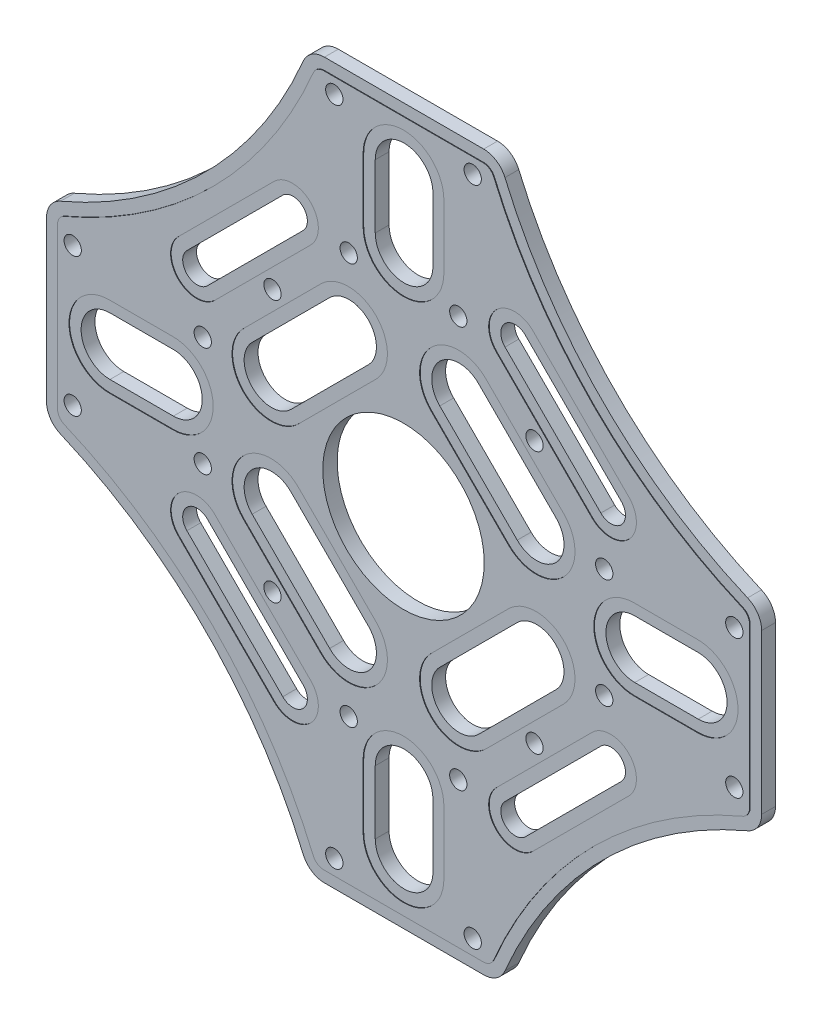
from build123d import *

# Parameters (mm, degrees)
CROQUIS1_R              = 14
SALIENTE_EXTRUIR1_DEPTH = 1.25
REDONDEO1_R             = 4
CORTAR_EXTRUIR1_DEPTH   = 0.1
CORTAR_EXTRUIR2_DEPTH   = 0.1
CROQUIS4_R              = 1.5
CORTAR_EXTRUIR3_DEPTH   = 10
CROQUIS5_R              = 1.5
CORTAR_EXTRUIR4_DEPTH   = 10


with BuildPart() as part:
    # Croquis1 → Saliente-Extruir1 (new body, symmetric)
    with BuildSketch(Plane.XY):
        with BuildLine():
            Line((16.5, -62), (-16.5, -62))
            ThreePointArc((-16.5, -62), (-34.432963769, -34.432963769), (-62, -16.5))
            Line((-62, -16.5), (-62, 16.5))
            ThreePointArc((-62, 16.5), (-34.432963769, 34.432963769), (-16.5, 62))
            Line((-16.5, 62), (16.5, 62))
            ThreePointArc((16.5, 62), (34.432963769, 34.432963769), (62, 16.5))
            Line((62, 16.5), (62, -16.5))
            ThreePointArc((62, -16.5), (34.432963769, -34.432963769), (16.5, -62))
        make_face()
        Circle(CROQUIS1_R, mode=Mode.SUBTRACT)
        with BuildLine():
            Line((5, 51), (5, 40))
            ThreePointArc((5, 40), (0, 35), (-5, 40))
            Line((-5, 40), (-5, 51))
            ThreePointArc((-5, 51), (0, 56), (5, 51))
        make_face(mode=Mode.SUBTRACT)
        with BuildLine():
            Line((51, -5), (40, -5))
            ThreePointArc((40, -5), (35, 0), (40, 5))
            Line((40, 5), (51, 5))
            ThreePointArc((51, 5), (56, 0), (51, -5))
        make_face(mode=Mode.SUBTRACT)
        with BuildLine():
            Line((-5, -51), (-5, -40))
            ThreePointArc((-5, -40), (0, -35), (5, -40))
            Line((5, -40), (5, -51))
            ThreePointArc((5, -51), (0, -56), (-5, -51))
        make_face(mode=Mode.SUBTRACT)
        with BuildLine():
            Line((-51, 5), (-40, 5))
            ThreePointArc((-40, 5), (-35, 0), (-40, -5))
            Line((-40, -5), (-51, -5))
            ThreePointArc((-51, -5), (-56, 0), (-51, 5))
        make_face(mode=Mode.SUBTRACT)
        with BuildLine():
            Line((-34.117902192, -17.500892834), (-17.500892834, -34.117902192))
            ThreePointArc((-17.500892834, -34.117902192), (-17.500892834, -37.653436098), (-21.03642674, -37.653436098))
            Line((-21.03642674, -37.653436098), (-37.653436098, -21.03642674))
            ThreePointArc((-37.653436098, -21.03642674), (-37.653436098, -17.500892834), (-34.117902192, -17.500892834))
        make_face(mode=Mode.SUBTRACT)
        with BuildLine():
            Line((-19.622213178, -6.187184335), (-6.187184335, -19.622213178))
            ThreePointArc((-6.187184335, -19.622213178), (-6.187184335, -26.339727599), (-12.904698757, -26.339727599))
            Line((-12.904698757, -26.339727599), (-26.339727599, -12.904698757))
            ThreePointArc((-26.339727599, -12.904698757), (-26.339727599, -6.187184335), (-19.622213178, -6.187184335))
        make_face(mode=Mode.SUBTRACT)
        with BuildLine():
            Line((17.500892834, -34.117902192), (34.117902192, -17.500892834))
            ThreePointArc((34.117902192, -17.500892834), (37.653436098, -17.500892834), (37.653436098, -21.03642674))
            Line((37.653436098, -21.03642674), (21.03642674, -37.653436098))
            ThreePointArc((21.03642674, -37.653436098), (17.500892834, -37.653436098), (17.500892834, -34.117902192))
        make_face(mode=Mode.SUBTRACT)
        with BuildLine():
            Line((6.187184335, -19.622213178), (19.622213178, -6.187184335))
            ThreePointArc((19.622213178, -6.187184335), (26.339727599, -6.187184335), (26.339727599, -12.904698757))
            Line((26.339727599, -12.904698757), (12.904698757, -26.339727599))
            ThreePointArc((12.904698757, -26.339727599), (6.187184335, -26.339727599), (6.187184335, -19.622213178))
        make_face(mode=Mode.SUBTRACT)
        with BuildLine():
            Line((-17.500892834, 34.117902192), (-34.117902192, 17.500892834))
            ThreePointArc((-34.117902192, 17.500892834), (-37.653436098, 17.500892834), (-37.653436098, 21.03642674))
            Line((-37.653436098, 21.03642674), (-21.03642674, 37.653436098))
            ThreePointArc((-21.03642674, 37.653436098), (-17.500892834, 37.653436098), (-17.500892834, 34.117902192))
        make_face(mode=Mode.SUBTRACT)
        with BuildLine():
            Line((-6.187184335, 19.622213178), (-19.622213178, 6.187184335))
            ThreePointArc((-19.622213178, 6.187184335), (-26.339727599, 6.187184335), (-26.339727599, 12.904698757))
            Line((-26.339727599, 12.904698757), (-12.904698757, 26.339727599))
            ThreePointArc((-12.904698757, 26.339727599), (-6.187184335, 26.339727599), (-6.187184335, 19.622213178))
        make_face(mode=Mode.SUBTRACT)
        with BuildLine():
            Line((34.117902192, 17.500892834), (17.500892834, 34.117902192))
            ThreePointArc((17.500892834, 34.117902192), (17.500892834, 37.653436098), (21.03642674, 37.653436098))
            Line((21.03642674, 37.653436098), (37.653436098, 21.03642674))
            ThreePointArc((37.653436098, 21.03642674), (37.653436098, 17.500892834), (34.117902192, 17.500892834))
        make_face(mode=Mode.SUBTRACT)
        with BuildLine():
            Line((19.622213178, 6.187184335), (6.187184335, 19.622213178))
            ThreePointArc((6.187184335, 19.622213178), (6.187184335, 26.339727599), (12.904698757, 26.339727599))
            Line((12.904698757, 26.339727599), (26.339727599, 12.904698757))
            ThreePointArc((26.339727599, 12.904698757), (26.339727599, 6.187184335), (19.622213178, 6.187184335))
        make_face(mode=Mode.SUBTRACT)
    extrude(amount=SALIENTE_EXTRUIR1_DEPTH, both=True)

    # Redondeo1
    redondeo1_edges = [part.edges().sort_by_distance(p)[0] for p in [
        (62, 16.5, 0),
        (62, -16.5, 0),
        (16.5, -62, 0),
        (-16.5, -62, 0),
        (-62, -16.5, 0),
        (-62, 16.5, 0),
        (-16.5, 62, 0),
        (16.5, 62, 0),
    ]]
    fillet(redondeo1_edges, radius=REDONDEO1_R)

    # Croquis2 → Cortar-Extruir1 (cut)
    with BuildSketch(Plane.XY.offset(1.25)):
        with BuildLine():
            Line((39.067649661, 22.450640303), (22.450640303, 39.067649661))
            ThreePointArc((22.450640303, 39.067649661), (16.086679272, 39.067649661), (16.086679272, 32.70368863))
            Line((16.086679272, 32.70368863), (32.70368863, 16.086679272))
            ThreePointArc((32.70368863, 16.086679272), (39.067649661, 16.086679272), (39.067649661, 22.450640303))
        make_face()
        with BuildLine():
            Line((37.653436098, 21.03642674), (21.03642674, 37.653436098))
            ThreePointArc((21.03642674, 37.653436098), (17.500892834, 37.653436098), (17.500892834, 34.117902192))
            Line((17.500892834, 34.117902192), (34.117902192, 17.500892834))
            ThreePointArc((34.117902192, 17.500892834), (37.653436098, 17.500892834), (37.653436098, 21.03642674))
        make_face(mode=Mode.SUBTRACT)
        with BuildLine():
            Line((18.207999616, 4.772970773), (4.772970773, 18.207999616))
            ThreePointArc((4.772970773, 18.207999616), (4.772970773, 27.753941162), (14.318912319, 27.753941162))
            Line((14.318912319, 27.753941162), (27.753941162, 14.318912319))
            ThreePointArc((27.753941162, 14.318912319), (27.753941162, 4.772970773), (18.207999616, 4.772970773))
        make_face()
        with BuildLine():
            Line((19.622213178, 6.187184335), (6.187184335, 19.622213178))
            ThreePointArc((6.187184335, 19.622213178), (6.187184335, 26.339727599), (12.904698757, 26.339727599))
            Line((12.904698757, 26.339727599), (26.339727599, 12.904698757))
            ThreePointArc((26.339727599, 12.904698757), (26.339727599, 6.187184335), (19.622213178, 6.187184335))
        make_face(mode=Mode.SUBTRACT)
        with BuildLine():
            Line((-14.318912319, 27.753941162), (-27.753941162, 14.318912319))
            ThreePointArc((-27.753941162, 14.318912319), (-27.753941162, 4.772970773), (-18.207999616, 4.772970773))
            Line((-18.207999616, 4.772970773), (-4.772970773, 18.207999616))
            ThreePointArc((-4.772970773, 18.207999616), (-4.772970773, 27.753941162), (-14.318912319, 27.753941162))
        make_face()
        with BuildLine():
            Line((-6.187184335, 19.622213178), (-19.622213178, 6.187184335))
            ThreePointArc((-19.622213178, 6.187184335), (-26.339727599, 6.187184335), (-26.339727599, 12.904698757))
            Line((-26.339727599, 12.904698757), (-12.904698757, 26.339727599))
            ThreePointArc((-12.904698757, 26.339727599), (-6.187184335, 26.339727599), (-6.187184335, 19.622213178))
        make_face(mode=Mode.SUBTRACT)
        with BuildLine():
            Line((-16.086679272, 32.70368863), (-32.70368863, 16.086679272))
            ThreePointArc((-32.70368863, 16.086679272), (-39.067649661, 16.086679272), (-39.067649661, 22.450640303))
            Line((-39.067649661, 22.450640303), (-22.450640303, 39.067649661))
            ThreePointArc((-22.450640303, 39.067649661), (-16.086679272, 39.067649661), (-16.086679272, 32.70368863))
        make_face()
        with BuildLine():
            Line((-17.500892834, 34.117902192), (-34.117902192, 17.500892834))
            ThreePointArc((-34.117902192, 17.500892834), (-37.653436098, 17.500892834), (-37.653436098, 21.03642674))
            Line((-37.653436098, 21.03642674), (-21.03642674, 37.653436098))
            ThreePointArc((-21.03642674, 37.653436098), (-17.500892834, 37.653436098), (-17.500892834, 34.117902192))
        make_face(mode=Mode.SUBTRACT)
        with BuildLine():
            Line((-7, 51), (-7, 40))
            ThreePointArc((-7, 40), (0, 33), (7, 40))
            Line((7, 40), (7, 51))
            ThreePointArc((7, 51), (0, 58), (-7, 51))
        make_face()
        with BuildLine():
            Line((5, 51), (5, 40))
            ThreePointArc((5, 40), (0, 35), (-5, 40))
            Line((-5, 40), (-5, 51))
            ThreePointArc((-5, 51), (0, 56), (5, 51))
        make_face(mode=Mode.SUBTRACT)
        with BuildLine():
            Line((-18.207999616, -4.772970773), (-4.772970773, -18.207999616))
            ThreePointArc((-4.772970773, -18.207999616), (-4.772970773, -27.753941162), (-14.318912319, -27.753941162))
            Line((-14.318912319, -27.753941162), (-27.753941162, -14.318912319))
            ThreePointArc((-27.753941162, -14.318912319), (-27.753941162, -4.772970773), (-18.207999616, -4.772970773))
        make_face()
        with BuildLine():
            Line((-19.622213178, -6.187184335), (-6.187184335, -19.622213178))
            ThreePointArc((-6.187184335, -19.622213178), (-6.187184335, -26.339727599), (-12.904698757, -26.339727599))
            Line((-12.904698757, -26.339727599), (-26.339727599, -12.904698757))
            ThreePointArc((-26.339727599, -12.904698757), (-26.339727599, -6.187184335), (-19.622213178, -6.187184335))
        make_face(mode=Mode.SUBTRACT)
        with BuildLine():
            Line((-51, -7), (-40, -7))
            ThreePointArc((-40, -7), (-33, 0), (-40, 7))
            Line((-40, 7), (-51, 7))
            ThreePointArc((-51, 7), (-58, 0), (-51, -7))
        make_face()
        with BuildLine():
            Line((-51, 5), (-40, 5))
            ThreePointArc((-40, 5), (-35, 0), (-40, -5))
            Line((-40, -5), (-51, -5))
            ThreePointArc((-51, -5), (-56, 0), (-51, 5))
        make_face(mode=Mode.SUBTRACT)
        with BuildLine():
            Line((-39.067649661, -22.450640303), (-22.450640303, -39.067649661))
            ThreePointArc((-22.450640303, -39.067649661), (-16.086679272, -39.067649661), (-16.086679272, -32.70368863))
            Line((-16.086679272, -32.70368863), (-32.70368863, -16.086679272))
            ThreePointArc((-32.70368863, -16.086679272), (-39.067649661, -16.086679272), (-39.067649661, -22.450640303))
        make_face()
        with BuildLine():
            Line((-34.117902192, -17.500892834), (-17.500892834, -34.117902192))
            ThreePointArc((-17.500892834, -34.117902192), (-17.500892834, -37.653436098), (-21.03642674, -37.653436098))
            Line((-21.03642674, -37.653436098), (-37.653436098, -21.03642674))
            ThreePointArc((-37.653436098, -21.03642674), (-37.653436098, -17.500892834), (-34.117902192, -17.500892834))
        make_face(mode=Mode.SUBTRACT)
        with BuildLine():
            Line((-7, -51), (-7, -40))
            ThreePointArc((-7, -40), (0, -33), (7, -40))
            Line((7, -40), (7, -51))
            ThreePointArc((7, -51), (0, -58), (-7, -51))
        make_face()
        with BuildLine():
            Line((-5, -51), (-5, -40))
            ThreePointArc((-5, -40), (0, -35), (5, -40))
            Line((5, -40), (5, -51))
            ThreePointArc((5, -51), (0, -56), (-5, -51))
        make_face(mode=Mode.SUBTRACT)
        with BuildLine():
            Line((14.318912319, -27.753941162), (27.753941162, -14.318912319))
            ThreePointArc((27.753941162, -14.318912319), (27.753941162, -4.772970773), (18.207999616, -4.772970773))
            Line((18.207999616, -4.772970773), (4.772970773, -18.207999616))
            ThreePointArc((4.772970773, -18.207999616), (4.772970773, -27.753941162), (14.318912319, -27.753941162))
        make_face()
        with BuildLine():
            Line((6.187184335, -19.622213178), (19.622213178, -6.187184335))
            ThreePointArc((19.622213178, -6.187184335), (26.339727599, -6.187184335), (26.339727599, -12.904698757))
            Line((26.339727599, -12.904698757), (12.904698757, -26.339727599))
            ThreePointArc((12.904698757, -26.339727599), (6.187184335, -26.339727599), (6.187184335, -19.622213178))
        make_face(mode=Mode.SUBTRACT)
        with BuildLine():
            Line((16.086679272, -32.70368863), (32.70368863, -16.086679272))
            ThreePointArc((32.70368863, -16.086679272), (39.067649661, -16.086679272), (39.067649661, -22.450640303))
            Line((39.067649661, -22.450640303), (22.450640303, -39.067649661))
            ThreePointArc((22.450640303, -39.067649661), (16.086679272, -39.067649661), (16.086679272, -32.70368863))
        make_face()
        with BuildLine():
            Line((17.500892834, -34.117902192), (34.117902192, -17.500892834))
            ThreePointArc((34.117902192, -17.500892834), (37.653436098, -17.500892834), (37.653436098, -21.03642674))
            Line((37.653436098, -21.03642674), (21.03642674, -37.653436098))
            ThreePointArc((21.03642674, -37.653436098), (17.500892834, -37.653436098), (17.500892834, -34.117902192))
        make_face(mode=Mode.SUBTRACT)
        with BuildLine():
            Line((51, -7), (40, -7))
            ThreePointArc((40, -7), (33, 0), (40, 7))
            Line((40, 7), (51, 7))
            ThreePointArc((51, 7), (58, 0), (51, -7))
        make_face()
        with BuildLine():
            Line((51, 5), (40, 5))
            ThreePointArc((40, 5), (35, 0), (40, -5))
            Line((40, -5), (51, -5))
            ThreePointArc((51, -5), (56, 0), (51, 5))
        make_face(mode=Mode.SUBTRACT)
    extrude(amount=-CORTAR_EXTRUIR1_DEPTH, mode=Mode.SUBTRACT)

    # Croquis3 → Cortar-Extruir2 (cut)
    with BuildSketch(Plane.XY.offset(1.25)):
        with BuildLine():
            Line((13.804536944, 62), (-13.804536944, 62))
            ThreePointArc((-13.804536944, 62), (-16.012629282, 61.335315311), (-17.486879036, 59.562164113))
            ThreePointArc((-17.486879036, 59.562164113), (-34.432963769, 34.432963769), (-59.562164113, 17.486879036))
            ThreePointArc((-59.562164113, 17.486879036), (-61.335315311, 16.012629282), (-62, 13.804536944))
            Line((-62, 13.804536944), (-62, -13.804536944))
            ThreePointArc((-62, -13.804536944), (-61.335315311, -16.012629282), (-59.562164113, -17.486879036))
            ThreePointArc((-59.562164113, -17.486879036), (-34.432963769, -34.432963769), (-17.486879036, -59.562164113))
            ThreePointArc((-17.486879036, -59.562164113), (-16.012629282, -61.335315311), (-13.804536944, -62))
            Line((-13.804536944, -62), (13.804536944, -62))
            ThreePointArc((13.804536944, -62), (16.012629282, -61.335315311), (17.486879036, -59.562164113))
            ThreePointArc((17.486879036, -59.562164113), (34.432963769, -34.432963769), (59.562164113, -17.486879036))
            ThreePointArc((59.562164113, -17.486879036), (61.335315311, -16.012629282), (62, -13.804536944))
            Line((62, -13.804536944), (62, 13.804536944))
            ThreePointArc((62, 13.804536944), (61.335315311, 16.012629282), (59.562164113, 17.486879036))
            ThreePointArc((59.562164113, 17.486879036), (34.432963769, 34.432963769), (17.486879036, 59.562164113))
            ThreePointArc((17.486879036, 59.562164113), (16.012629282, 61.335315311), (13.804536944, 62))
        make_face()
        with BuildLine():
            Line((60, -13.804536944), (60, 13.804536944))
            ThreePointArc((60, 13.804536944), (59.667657656, 14.908583113), (58.781082056, 15.64570799))
            ThreePointArc((58.781082056, 15.64570799), (33.018750207, 33.018750207), (15.64570799, 58.781082056))
            ThreePointArc((15.64570799, 58.781082056), (14.908583113, 59.667657656), (13.804536944, 60))
            Line((13.804536944, 60), (-13.804536944, 60))
            ThreePointArc((-13.804536944, 60), (-14.908583113, 59.667657656), (-15.64570799, 58.781082056))
            ThreePointArc((-15.64570799, 58.781082056), (-33.018750207, 33.018750207), (-58.781082056, 15.64570799))
            ThreePointArc((-58.781082056, 15.64570799), (-59.667657656, 14.908583113), (-60, 13.804536944))
            Line((-60, 13.804536944), (-60, -13.804536944))
            ThreePointArc((-60, -13.804536944), (-59.667657656, -14.908583113), (-58.781082056, -15.64570799))
            ThreePointArc((-58.781082056, -15.64570799), (-33.018750207, -33.018750207), (-15.64570799, -58.781082056))
            ThreePointArc((-15.64570799, -58.781082056), (-14.908583113, -59.667657656), (-13.804536944, -60))
            Line((-13.804536944, -60), (13.804536944, -60))
            ThreePointArc((13.804536944, -60), (14.908583113, -59.667657656), (15.64570799, -58.781082056))
            ThreePointArc((15.64570799, -58.781082056), (33.018750207, -33.018750207), (58.781082056, -15.64570799))
            ThreePointArc((58.781082056, -15.64570799), (59.667657656, -14.908583113), (60, -13.804536944))
        make_face(mode=Mode.SUBTRACT)
    extrude(amount=-CORTAR_EXTRUIR2_DEPTH, mode=Mode.SUBTRACT)

    # Croquis4 → Cortar-Extruir3 (cut)
    with BuildSketch(Plane.XY.offset(1.25)):
        with Locations((57.357970718, 12)):
            Circle(CROQUIS4_R)
        with Locations((57.357970718, -12)):
            Circle(CROQUIS4_R)
        with Locations((34.807865642, 9.5)):
            Circle(CROQUIS4_R)
        with Locations((34.807865642, -9.5)):
            Circle(CROQUIS4_R)
        with Locations((12, -57.357970718)):
            Circle(CROQUIS4_R)
        with Locations((-12, -57.357970718)):
            Circle(CROQUIS4_R)
        with Locations((-9.5, -34.807865642)):
            Circle(CROQUIS4_R)
        with Locations((9.5, -34.807865642)):
            Circle(CROQUIS4_R)
        with Locations((-57.357970718, -12)):
            Circle(CROQUIS4_R)
        with Locations((-57.357970718, 12)):
            Circle(CROQUIS4_R)
        with Locations((-34.807865642, 9.5)):
            Circle(CROQUIS4_R)
        with Locations((-34.807865642, -9.5)):
            Circle(CROQUIS4_R)
        with Locations((-12, 57.357970718)):
            Circle(CROQUIS4_R)
        with Locations((12, 57.357970718)):
            Circle(CROQUIS4_R)
        with Locations((9.5, 34.807865642)):
            Circle(CROQUIS4_R)
        with Locations((-9.5, 34.807865642)):
            Circle(CROQUIS4_R)
    extrude(amount=-CORTAR_EXTRUIR3_DEPTH, mode=Mode.SUBTRACT)

    # Croquis5 → Cortar-Extruir4 (cut)
    with BuildSketch(Plane.XY.offset(1.25)):
        with Locations((-22.715805346, 22.715805346)):
            Circle(CROQUIS5_R)
        with Locations((22.715805346, 22.715805346)):
            Circle(CROQUIS5_R)
        with Locations((22.715805346, -22.715805346)):
            Circle(CROQUIS5_R)
        with Locations((-22.715805346, -22.715805346)):
            Circle(CROQUIS5_R)
    extrude(amount=-CORTAR_EXTRUIR4_DEPTH, mode=Mode.SUBTRACT)


solid = part.part
